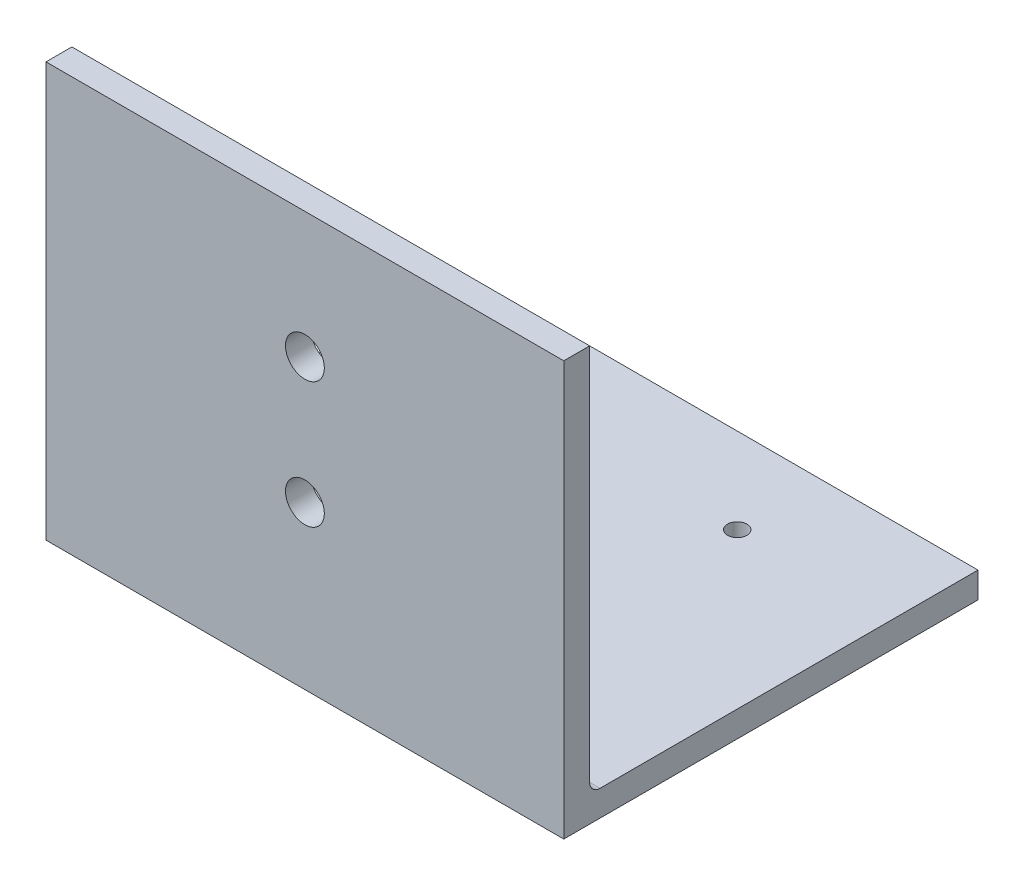
from build123d import *

# Parameters (mm, degrees)
BOSS_EXTRUDE1_DEPTH = 127
FILLET1_R           = 2.54
SKETCH2_R           = 4.7625
CUT_EXTRUDE1_DEPTH  = 6.35
SKETCH3_R           = 2.38125
CUT_EXTRUDE2_DEPTH  = 6.35


with BuildPart() as part:
    # Sketch1 → Boss-Extrude1 (new body)
    with BuildSketch(Plane(origin=(0, 0, 0), x_dir=(0, 0, -1), z_dir=(1, 0, 0))):
        Polygon((0, 0), (0, 101.6), (6.35, 101.6), (6.35, 6.35), (101.6, 6.35), (101.6, 0), align=None)
    extrude(amount=BOSS_EXTRUDE1_DEPTH)

    # Fillet1
    fillet1_edges = [part.edges().sort_by_distance(p)[0] for p in [
        (63.5, 6.35, -6.35),
    ]]
    fillet(fillet1_edges, radius=FILLET1_R)

    # Sketch2 → Cut-Extrude1 (cut)
    with BuildSketch(Plane(origin=(0, 0, -6.35), x_dir=(-1, 0, 0), z_dir=(0, 0, -1))):
        with Locations((-63.5, 70.696666667)):
            Circle(SKETCH2_R)
        with Locations((-63.5, 39.793333249)):
            Circle(SKETCH2_R)
    extrude(amount=-CUT_EXTRUDE1_DEPTH, mode=Mode.SUBTRACT)

    # Sketch3 → Cut-Extrude2 (cut)
    with BuildSketch(Plane(origin=(0, 6.35, 0), x_dir=(1, 0, 0), z_dir=(0, 1, 0))):
        with Locations((38.1, 80.645)):
            Circle(SKETCH3_R)
        with Locations((88.9, 80.645)):
            Circle(SKETCH3_R)
        with Locations((38.1, 29.845)):
            Circle(SKETCH3_R)
        with Locations((88.9, 29.845)):
            Circle(SKETCH3_R)
    extrude(amount=-CUT_EXTRUDE2_DEPTH, mode=Mode.SUBTRACT)


solid = part.part
